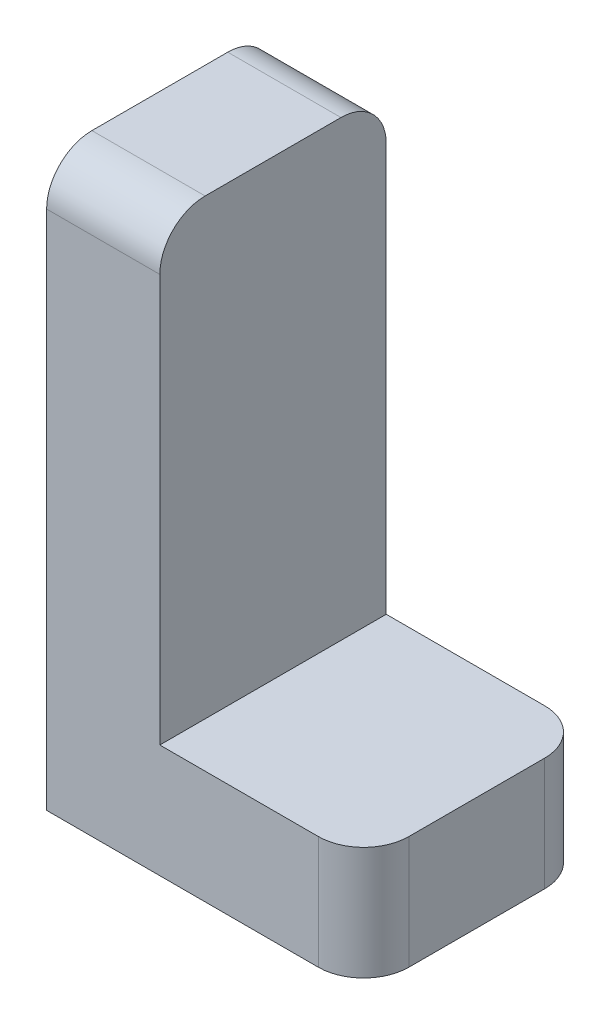
from build123d import *

# Parameters (mm, degrees)
BOSS_EXTRUDE1_DEPTH = 10
FILLET1_R           = 2
FILLET2_R           = 2
FILLET3_R           = 2
FILLET4_R           = 2
SKETCH2_W           = 11.181044811
SKETCH2_H           = 7.229971792
CUT_EXTRUDE1_DEPTH  = 4


with BuildPart() as part:
    # Sketch1 → Boss-Extrude1 (new body)
    with BuildSketch(Plane.XY):
        Polygon((14, 0), (0, 0), (0, 25), (5, 25), (5, 5), (14, 5), align=None)
    extrude(amount=BOSS_EXTRUDE1_DEPTH)

    # Fillet1
    fillet1_edges = [part.edges().sort_by_distance(p)[0] for p in [
        (2.5, 25, 10),
    ]]
    fillet(fillet1_edges, radius=FILLET1_R)

    # Fillet2
    fillet2_edges = [part.edges().sort_by_distance(p)[0] for p in [
        (2.5, 25, 0),
    ]]
    fillet(fillet2_edges, radius=FILLET2_R)

    # Fillet3
    fillet3_edges = [part.edges().sort_by_distance(p)[0] for p in [
        (14, 2.5, 10),
    ]]
    fillet(fillet3_edges, radius=FILLET3_R)

    # Fillet4
    fillet4_edges = [part.edges().sort_by_distance(p)[0] for p in [
        (14, 2.5, 0),
    ]]
    fillet(fillet4_edges, radius=FILLET4_R)

    # Sketch2 → Cut-Extrude1 (cut)
    with BuildSketch(Plane.XZ):
        with Locations((6.674906448, 5.176903909)):
            Rectangle(SKETCH2_W, SKETCH2_H)
    extrude(amount=-CUT_EXTRUDE1_DEPTH, mode=Mode.SUBTRACT)


solid = part.part
